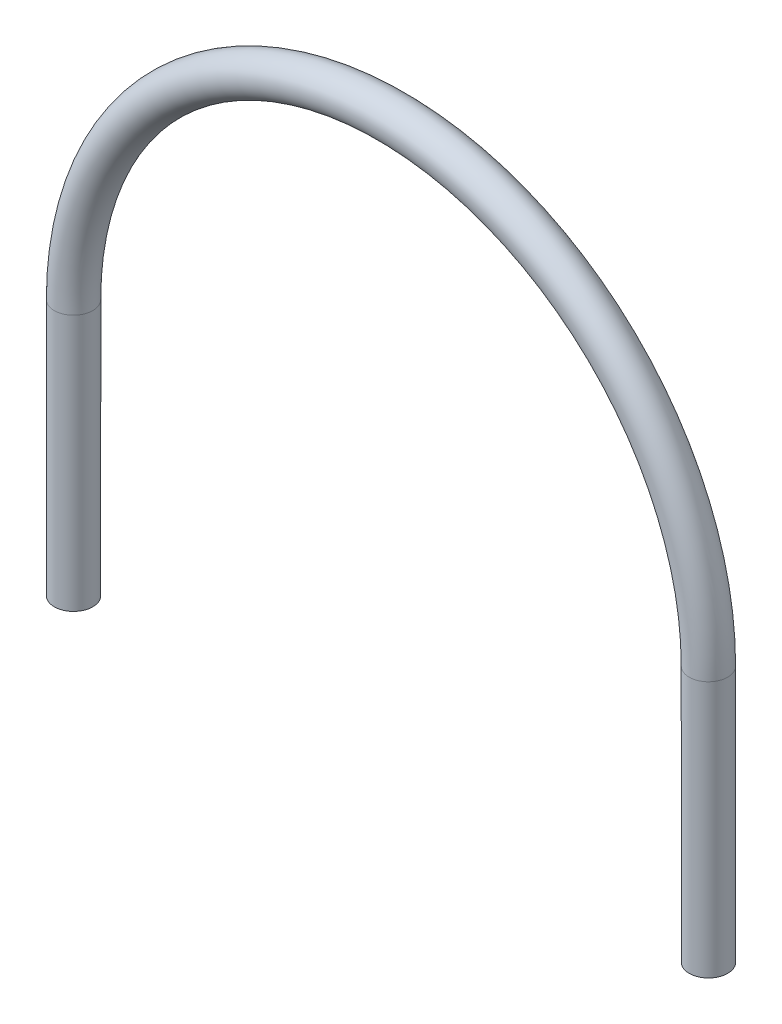
from build123d import *

# Parameters (mm, degrees)
SWEEP_THIN1_PROFILE_R   = 30
SWEEP_THIN1_PROFILE_R_2 = 27


with BuildPart() as part:
    # Sweep-Thin1: sweep along a path in Sketch1
    with BuildLine(Plane.XY) as sweep_thin1_path:
        Line((-476.383795026, -400), (-476.383795026, 0))
        ThreePointArc((-476.383795026, 0), (18.616204974, 495), (513.616204974, 0))
        Line((513.616204974, 0), (513.616204974, -400))
    # Sweep-Thin1 profile (on start of the path) → Sweep-Thin1 (sweep)
    with BuildSketch(Plane(origin=(-476.383795026, -400, 0), x_dir=(0, 0, 1), z_dir=(0, 1, 0))):
        Circle(SWEEP_THIN1_PROFILE_R)
        Circle(SWEEP_THIN1_PROFILE_R_2, mode=Mode.SUBTRACT)
    sweep(path=sweep_thin1_path.line)


solid = part.part
